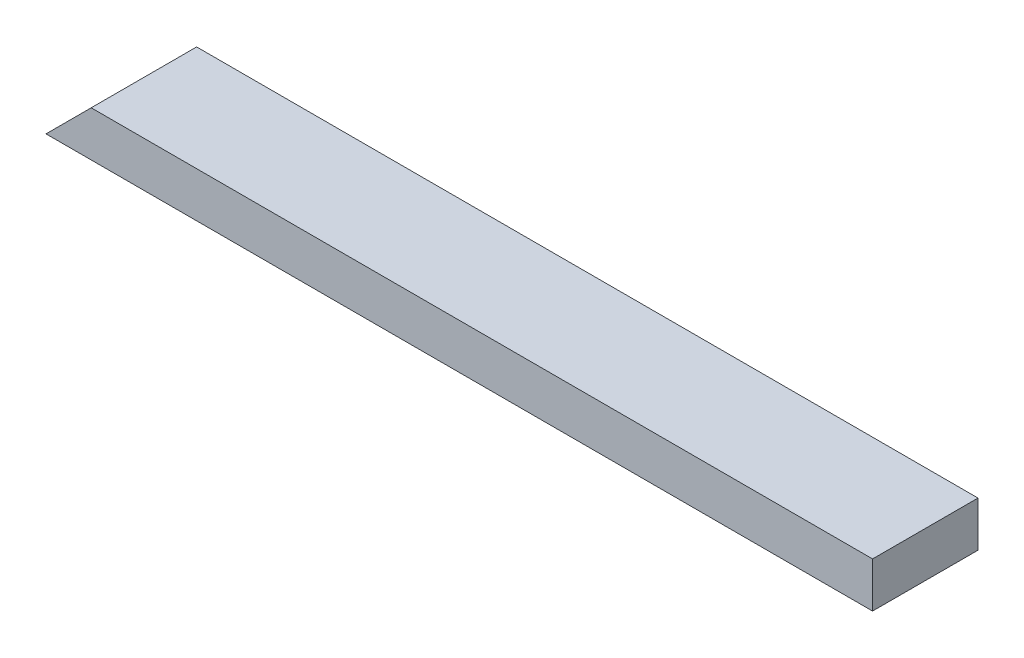
from build123d import *

# Parameters (mm, degrees)
SKETCH1_W           = 696.9125
SKETCH1_H           = 88.9
BOSS_EXTRUDE1_DEPTH = 38.1
CUT_EXTRUDE1_DEPTH  = 89.9


with BuildPart() as part:
    # Sketch1 → Boss-Extrude1 (new body)
    with BuildSketch(Plane(origin=(0, 0, 0), x_dir=(1, 0, 0), z_dir=(0, 1, 0))):
        with Locations((348.45625, 44.45)):
            Rectangle(SKETCH1_W, SKETCH1_H)
    extrude(amount=BOSS_EXTRUDE1_DEPTH)

    # Sketch2 → Cut-Extrude1 (cut, through all)
    with BuildSketch(Plane.XY):
        Polygon((0, 0), (38.1, 38.1), (0, 38.1), align=None)
    extrude(amount=-CUT_EXTRUDE1_DEPTH, mode=Mode.SUBTRACT)


solid = part.part
